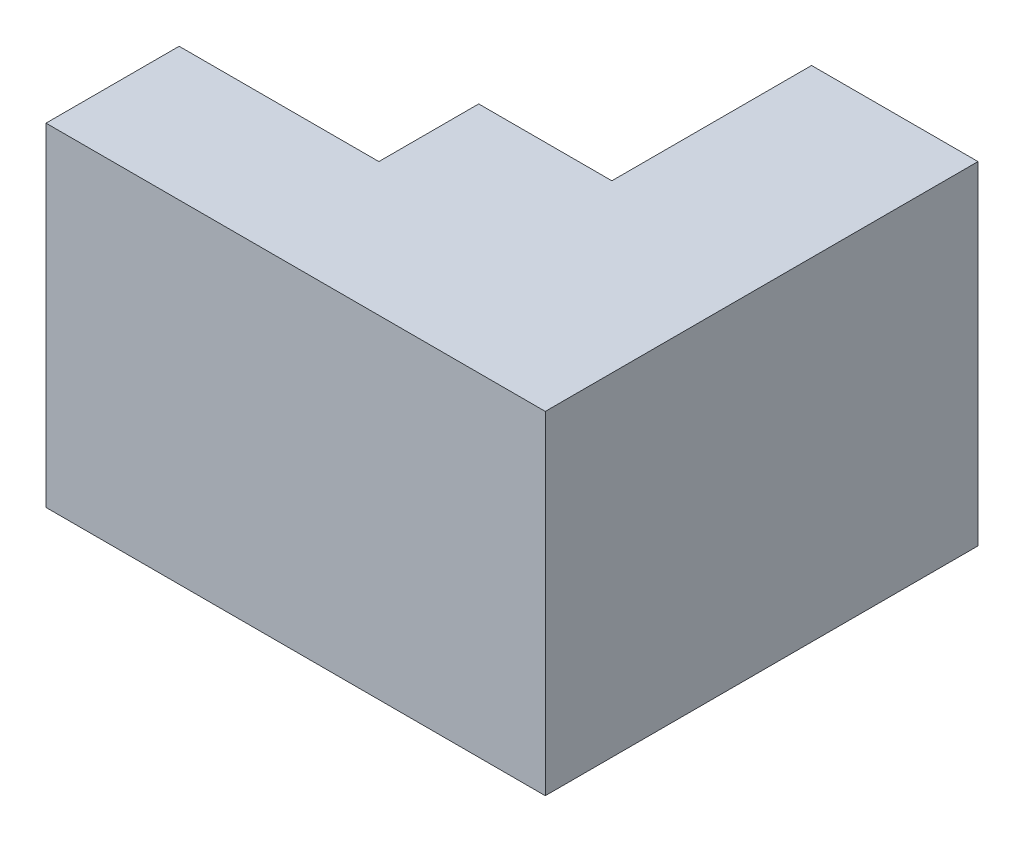
from build123d import *

# Parameters (mm, degrees)
BOSS_EXTRUDE1_DEPTH = 50


with BuildPart() as part:
    # Sketch1 → Boss-Extrude1 (new body)
    with BuildSketch(Plane(origin=(0, 0, 0), x_dir=(1, 0, 0), z_dir=(0, 1, 0))):
        Polygon((0, 0), (75, 0), (75, 65), (50, 65), (50, 35), (30, 35), (30, 20), (0, 20), align=None)
    extrude(amount=BOSS_EXTRUDE1_DEPTH)


solid = part.part
